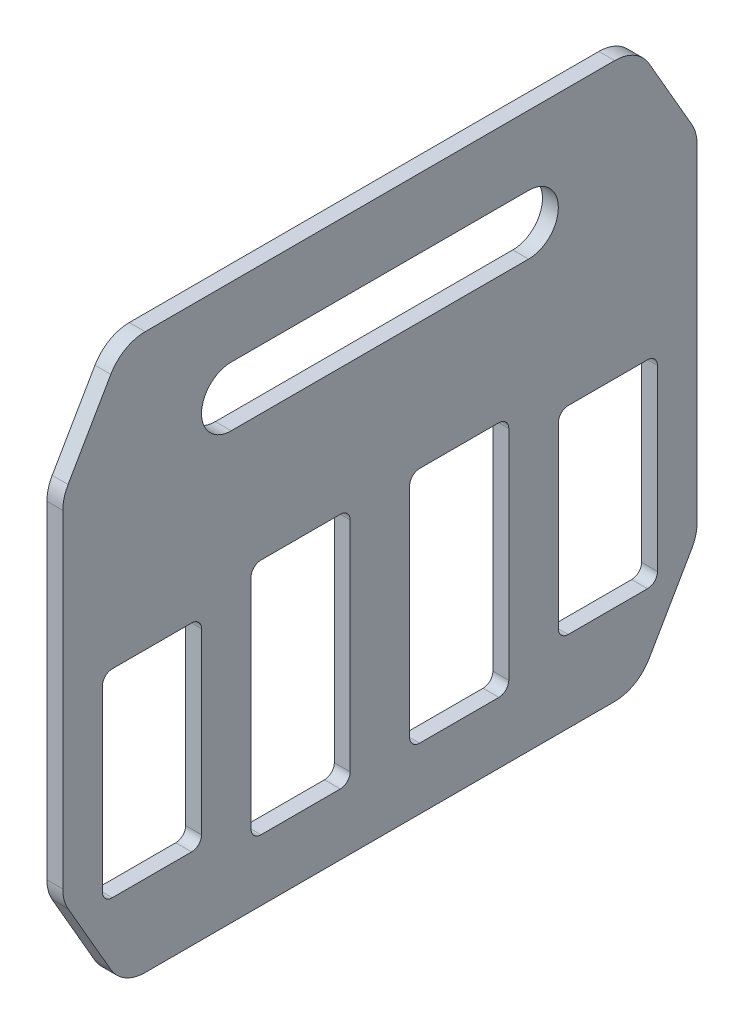
from build123d import *

# Parameters (mm, degrees)
BOSS_EXTRUDE1_DEPTH   = 10.16
SKETCH2_W             = 76.2
SKETCH2_H             = 10.16
CUT_EXTRUDE1_DEPTH    = 4.572
CHAMFER1_SIZE         = 38.1
CHAMFER1_SIZE2        = 65.991135768
CHAMFER1_PART_2_SIZE  = 38.1
CHAMFER1_PART_2_SIZE2 = 65.991135768
FILLET1_R             = 25.4
CUT_EXTRUDE2_DEPTH    = 26.416


with BuildPart() as part:
    # Sketch1 → Boss-Extrude1 (new body)
    with BuildSketch(Plane(origin=(0, 0, 0), x_dir=(0, 0, -1), z_dir=(1, 0, 0))):
        Polygon((-203.2, 0), (-203.2, 254), (-203.2, 279.4), (203.2, 279.4), (203.2, 254), (203.2, 0), (203.2, -76.2), (-203.2, -76.2), align=None)
        with BuildLine():
            Line((-95.25, 234.95), (95.25, 234.95))
            ThreePointArc((95.25, 234.95), (114.3, 215.9), (95.25, 196.85))
            Line((95.25, 196.85), (-95.25, 196.85))
            ThreePointArc((-95.25, 196.85), (-114.3, 215.9), (-95.25, 234.95))
        make_face(mode=Mode.SUBTRACT)
    extrude(amount=BOSS_EXTRUDE1_DEPTH)

    # Sketch2 → Cut-Extrude1 (cut)
    with BuildSketch(Plane(origin=(0, 0, 0), x_dir=(0, 0, -1), z_dir=(1, 0, 0))):
        with Locations((-158.75, 127)):
            Rectangle(SKETCH2_W, SKETCH2_H)
        with Locations((0, 127)):
            Rectangle(SKETCH2_W, SKETCH2_H)
        with Locations((158.75, 127)):
            Rectangle(SKETCH2_W, SKETCH2_H)
    extrude(amount=CUT_EXTRUDE1_DEPTH, mode=Mode.SUBTRACT)

    # Chamfer1
    chamfer1_edges = [part.edges().sort_by_distance(p)[0] for p in [
        (5.08, 279.4, 203.2),
        (5.08, 279.4, -203.2),
    ]]
    chamfer1_side = [part.faces().sort_by_distance(p)[0] for p in [
        (5.08, 279.4, 0),
    ]]
    chamfer(chamfer1_edges, length=CHAMFER1_SIZE, length2=CHAMFER1_SIZE2, reference=chamfer1_side[0])

    # Chamfer1 part 2
    chamfer1_part_2_edges = [part.edges().sort_by_distance(p)[0] for p in [
        (5.08, -76.2, -203.2),
        (5.08, -76.2, 203.2),
    ]]
    chamfer1_part_2_side = [part.faces().sort_by_distance(p)[0] for p in [
        (5.08, -76.2, 0),
    ]]
    chamfer(chamfer1_part_2_edges, length=CHAMFER1_PART_2_SIZE, length2=CHAMFER1_PART_2_SIZE2, reference=chamfer1_part_2_side[0])

    # Fillet1
    fillet1_edges = [part.edges().sort_by_distance(p)[0] for p in [
        (5.08, 213.408864232, -203.2),
        (5.08, -10.208864232, -203.2),
        (5.08, -76.2, 165.1),
        (5.08, -76.2, -165.1),
        (5.08, 213.408864232, 203.2),
        (5.08, -10.208864232, 203.2),
        (5.08, 279.4, -165.1),
        (5.08, 279.4, 165.1),
    ]]
    fillet(fillet1_edges, radius=FILLET1_R)

    # Sketch4 → Cut-Extrude2 (cut)
    with BuildSketch(Plane(origin=(0, 0, 0), x_dir=(0, 0, -1), z_dir=(1, 0, 0))):
        with BuildLine():
            Line((-171.45, 102.87), (-120.65, 102.87))
            ThreePointArc((-120.65, 102.87), (-116.159871939, 101.010128061), (-114.3, 96.52))
            Line((-114.3, 96.52), (-114.3, -17.78))
            ThreePointArc((-114.3, -17.78), (-116.159871939, -22.270128061), (-120.65, -24.13))
            Line((-120.65, -24.13), (-171.45, -24.13))
            ThreePointArc((-171.45, -24.13), (-175.940128061, -22.270128061), (-177.8, -17.78))
            Line((-177.8, -17.78), (-177.8, 96.52))
            ThreePointArc((-177.8, 96.52), (-175.940128061, 101.010128061), (-171.45, 102.87))
        make_face()
        with BuildLine():
            Line((-76.2, 115.57), (-25.4, 115.57))
            ThreePointArc((-25.4, 115.57), (-20.909871939, 113.710128061), (-19.05, 109.22))
            Line((-19.05, 109.22), (-19.05, -30.48))
            ThreePointArc((-19.05, -30.48), (-20.909871939, -34.970128061), (-25.4, -36.83))
            Line((-25.4, -36.83), (-76.2, -36.83))
            ThreePointArc((-76.2, -36.83), (-80.690128061, -34.970128061), (-82.55, -30.48))
            Line((-82.55, -30.48), (-82.55, 109.22))
            ThreePointArc((-82.55, 109.22), (-80.690128061, 113.710128061), (-76.2, 115.57))
        make_face()
        with BuildLine():
            Line((19.05, 109.22), (19.05, -30.48))
            ThreePointArc((19.05, -30.48), (20.909871939, -34.970128061), (25.4, -36.83))
            Line((25.4, -36.83), (76.2, -36.83))
            ThreePointArc((76.2, -36.83), (80.690128061, -34.970128061), (82.55, -30.48))
            Line((82.55, -30.48), (82.55, 109.22))
            ThreePointArc((82.55, 109.22), (80.690128061, 113.710128061), (76.2, 115.57))
            Line((76.2, 115.57), (25.4, 115.57))
            ThreePointArc((25.4, 115.57), (20.909871939, 113.710128061), (19.05, 109.22))
        make_face()
        with BuildLine():
            Line((114.3, 96.52), (114.3, -17.78))
            ThreePointArc((114.3, -17.78), (116.159871939, -22.270128061), (120.65, -24.13))
            Line((120.65, -24.13), (171.45, -24.13))
            ThreePointArc((171.45, -24.13), (175.940128061, -22.270128061), (177.8, -17.78))
            Line((177.8, -17.78), (177.8, 96.52))
            ThreePointArc((177.8, 96.52), (175.940128061, 101.010128061), (171.45, 102.87))
            Line((171.45, 102.87), (120.65, 102.87))
            ThreePointArc((120.65, 102.87), (116.159871939, 101.010128061), (114.3, 96.52))
        make_face()
    extrude(amount=CUT_EXTRUDE2_DEPTH, mode=Mode.SUBTRACT)


solid = part.part
